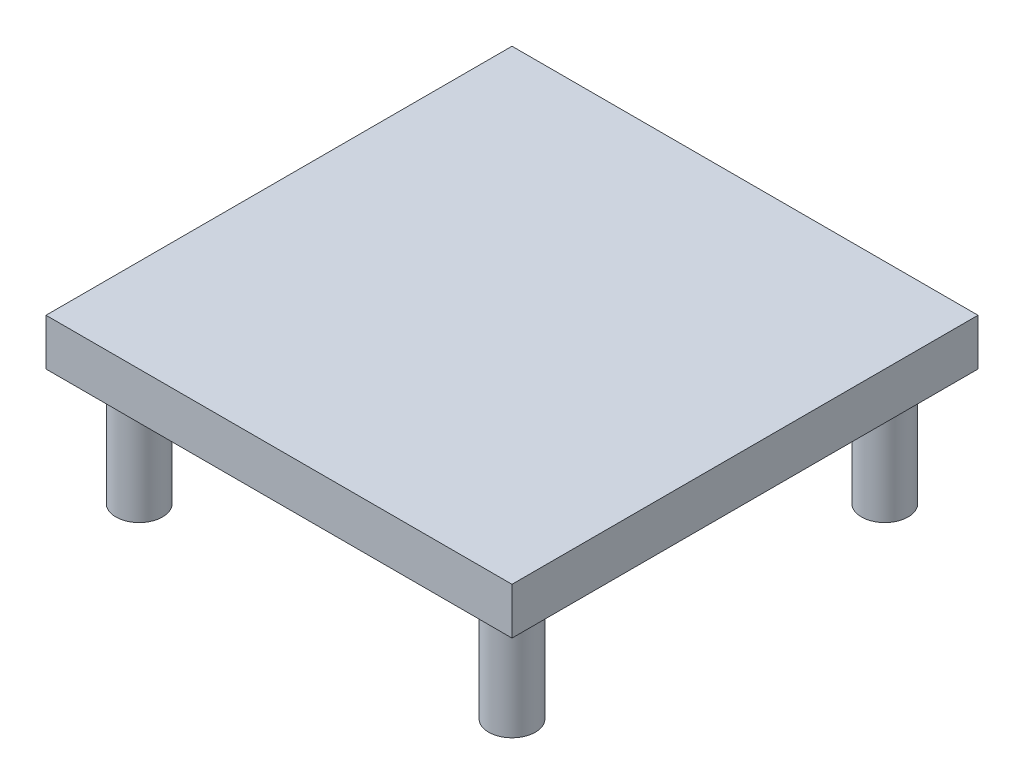
from build123d import *

# Parameters (mm, degrees)
SKETCH1_W           = 200
SKETCH1_H           = 200
BOSS_EXTRUDE1_DEPTH = 20
SKETCH2_R           = 10
BOSS_EXTRUDE2_DEPTH = 50


with BuildPart() as part:
    # Sketch1 → Boss-Extrude1 (new body)
    with BuildSketch(Plane(origin=(0, 0, 0), x_dir=(1, 0, 0), z_dir=(0, 1, 0))):
        Rectangle(SKETCH1_W, SKETCH1_H)
    extrude(amount=BOSS_EXTRUDE1_DEPTH)

    # Sketch2 → Boss-Extrude2 (add)
    with BuildSketch(Plane.XZ):
        with Locations((80, 80)):
            Circle(SKETCH2_R)
        with Locations((80, -80)):
            Circle(SKETCH2_R)
        with Locations((-80, -80)):
            Circle(SKETCH2_R)
        with Locations((-80, 80)):
            Circle(SKETCH2_R)
    extrude(amount=BOSS_EXTRUDE2_DEPTH)


solid = part.part
